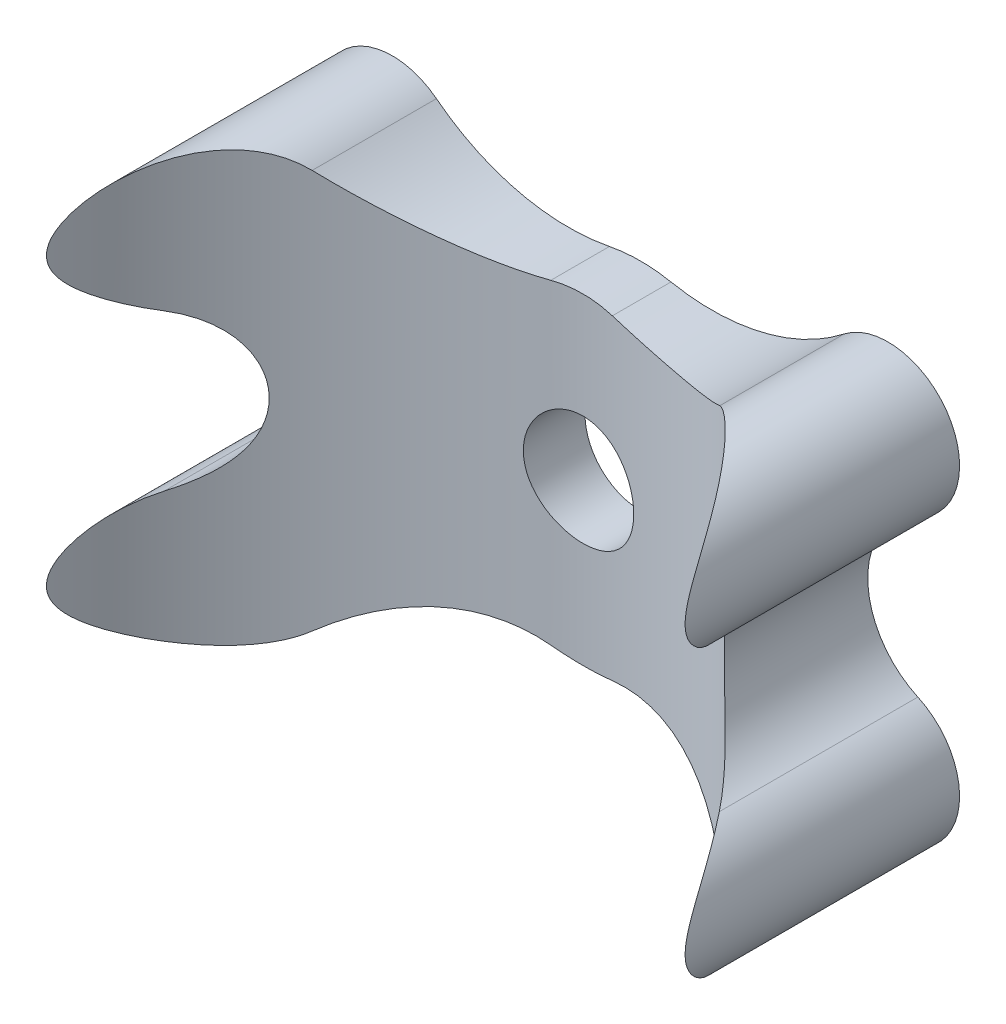
from build123d import *

# Parameters (mm, degrees)
SKETCH2_W                           = 30.48
SKETCH2_H                           = 152.4
BOSS_EXTRUDE1_DEPTH                 = 25.4
BOSS_EXTRUDE1_DEPTH_BACK            = 5.08
SKETCH4_R                           = 4.89966
F_8_0_199_DIAMETER_HOLE1_AT_2_COUNT = 2
F_8_0_199_DIAMETER_HOLE1_AT_2_PITCH = 50.8
F_8_0_199_DIAMETER_HOLE1_AT_3_COUNT = 2
F_8_0_199_DIAMETER_HOLE1_AT_3_PITCH = 43.994090512
F_8_0_199_DIAMETER_HOLE1_AT_4_COUNT = 2
F_8_0_199_DIAMETER_HOLE1_AT_4_PITCH = 25.4


with BuildPart() as part:
    # Sketch2 → Revolve1 (revolve)
    with BuildSketch(Plane(origin=(0, 0, 0), x_dir=(0, 0, -1), z_dir=(1, 0, 0))):
        with Locations((15.24, 0)):
            Rectangle(SKETCH2_W, SKETCH2_H)
    revolve(axis=Axis((0, -76.2, 0), (0, 1, 0)))


with BuildPart() as body_2:
    # Sketch4 → Boss-Extrude1 (new, two sides: drawn at the far end of the back side and taken through both)
    with BuildSketch(Plane(origin=(0, 0, -30.48), x_dir=(-1, 0, 0), z_dir=(0, 0, 1)).offset(-BOSS_EXTRUDE1_DEPTH_BACK)):
        with BuildLine():
            ThreePointArc((-24.642441225, -6.927272727), (-20.196916389, 0), (-24.642441225, 6.927272727))
            ThreePointArc((-24.642441225, 6.927272727), (-27.423118543, 15.998519166), (-18.090128015, 17.705846349))
            ThreePointArc((-18.090128015, 17.705846349), (-10.809478571, 14.198051615), (-2.729732697, 14.024308028))
            ThreePointArc((-2.729732697, 14.024308028), (0, 14.2875), (2.729732697, 14.024308028))
            ThreePointArc((2.729732697, 14.024308028), (10.809478571, 14.198051615), (18.090128015, 17.705846349))
            ThreePointArc((18.090128015, 17.705846349), (27.423118543, 15.998519166), (24.642441225, 6.927272727))
            ThreePointArc((24.642441225, 6.927272727), (20.196916389, 0), (24.642441225, -6.927272727))
            ThreePointArc((24.642441225, -6.927272727), (27.423118543, -15.998519166), (18.090128015, -17.705846349))
            ThreePointArc((18.090128015, -17.705846349), (10.809478571, -14.198051615), (2.729732697, -14.024308028))
            ThreePointArc((2.729732697, -14.024308028), (0, -14.2875), (-2.729732697, -14.024308028))
            ThreePointArc((-2.729732697, -14.024308028), (-10.809478571, -14.198051615), (-18.090128015, -17.705846349))
            ThreePointArc((-18.090128015, -17.705846349), (-27.423118543, -15.998519166), (-24.642441225, -6.927272727))
        make_face()
        Circle(SKETCH4_R, mode=Mode.SUBTRACT)
    extrude(amount=BOSS_EXTRUDE1_DEPTH + BOSS_EXTRUDE1_DEPTH_BACK)

    # Sketch10 → 8 _0.199_ Diameter Hole1 (revolve, cut)
    with BuildSketch(Plane(origin=(-21.997045256, 12.7, -35.56), x_dir=(0, 1, 0), z_dir=(1, 0, 0))):
        Polygon((0, 0), (0, 6.598555042), (2.5273, 5.08), (2.5273, 0), align=None)
    f_8_0_199_diameter_hole1 = revolve(axis=Axis((-21.997045256, 12.7, -41.91), (0, 0, 1)), mode=Mode.SUBTRACT)

    # 8 _0.199_ Diameter Hole1 at 2: 8 _0.199_ Diameter Hole1 ×2
    with Locations(*[Vector(0.8660254037844379, -0.5000000000000014, -6.031920370010707e-15) * (i * F_8_0_199_DIAMETER_HOLE1_AT_2_PITCH) for i in range(1, F_8_0_199_DIAMETER_HOLE1_AT_2_COUNT)]):
        add(f_8_0_199_diameter_hole1, mode=Mode.SUBTRACT)

    # 8 _0.199_ Diameter Hole1 at 3: 8 _0.199_ Diameter Hole1 ×2
    with Locations(*[(i * F_8_0_199_DIAMETER_HOLE1_AT_3_PITCH, 0, 0) for i in range(1, F_8_0_199_DIAMETER_HOLE1_AT_3_COUNT)]):
        add(f_8_0_199_diameter_hole1, mode=Mode.SUBTRACT)

    # 8 _0.199_ Diameter Hole1 at 4: 8 _0.199_ Diameter Hole1 ×2
    with Locations(*[(0, -i * F_8_0_199_DIAMETER_HOLE1_AT_4_PITCH, 0) for i in range(1, F_8_0_199_DIAMETER_HOLE1_AT_4_COUNT)]):
        add(f_8_0_199_diameter_hole1, mode=Mode.SUBTRACT)

    # Combine4: cut part
    add(part.part, mode=Mode.SUBTRACT)


solid = body_2.part
